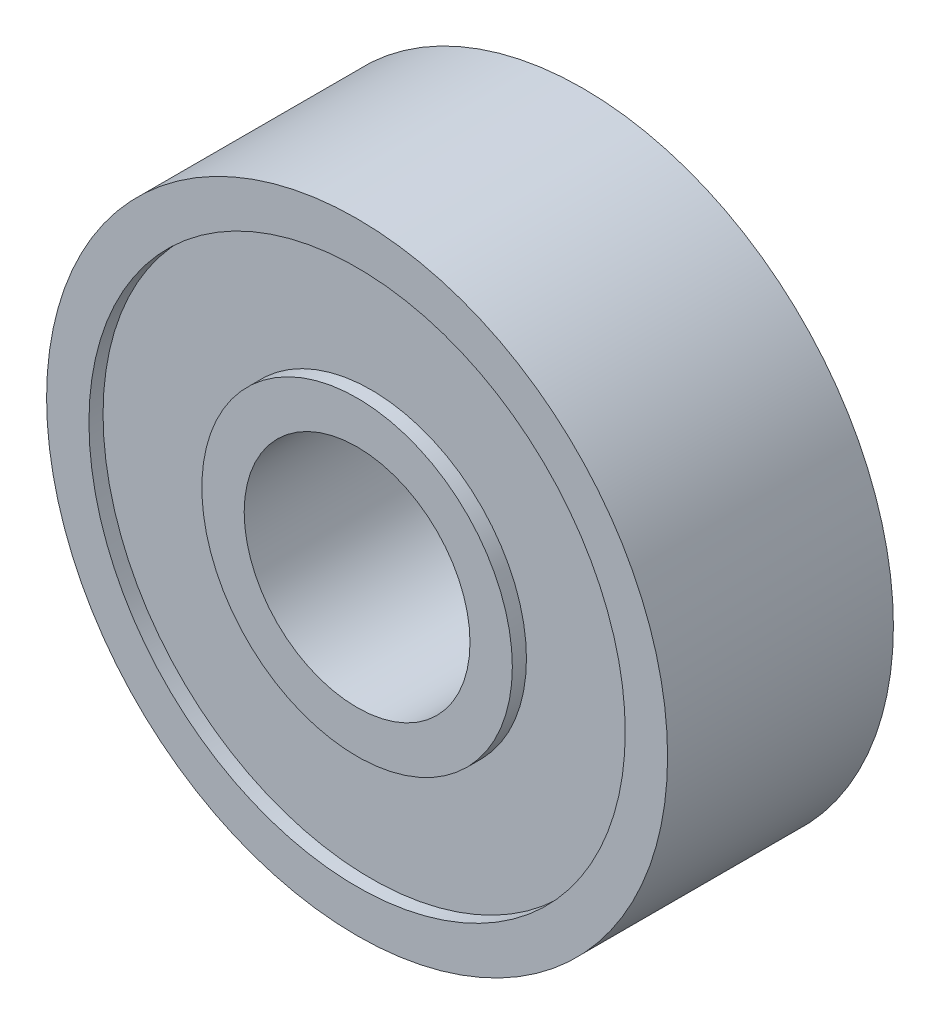
from build123d import *

# Parameters (mm, degrees)
SALIENTE_EXTRUIR1_DEPTH        = 4
SALIENTE_EXTRUIR1_DEPTH_BACK   = 4
CROQUIS1_R                     = 11
CROQUIS1_R_2                   = 9.5
SALIENTE_EXTRUIR1_2_DEPTH      = 4
SALIENTE_EXTRUIR1_2_DEPTH_BACK = 4
CROQUIS1_R_3                   = 5.5
CROQUIS1_R_4                   = 4
SALIENTE_EXTRUIR2_DEPTH        = 3.5
SALIENTE_EXTRUIR2_DEPTH_BACK   = 3.5
CROQUIS1_4_R                   = 9.5
CROQUIS1_4_R_2                 = 5.5


with BuildPart() as part:
    # Croquis1 → Saliente-Extruir1 (new, two sides: drawn at the far end of the back side and taken through both)
    with BuildSketch(Plane.XY.offset(-SALIENTE_EXTRUIR1_DEPTH_BACK)):
        Circle(CROQUIS1_R)
        Circle(CROQUIS1_R_2, mode=Mode.SUBTRACT)
    extrude(amount=SALIENTE_EXTRUIR1_DEPTH + SALIENTE_EXTRUIR1_DEPTH_BACK)



with BuildPart() as body_2:
    # Croquis1 → Saliente-Extruir1 2 (new, two sides: drawn at the far end of the back side and taken through both)
    with BuildSketch(Plane.XY.offset(-SALIENTE_EXTRUIR1_2_DEPTH_BACK)):
        Circle(CROQUIS1_R_3)
        Circle(CROQUIS1_R_4, mode=Mode.SUBTRACT)
    extrude(amount=SALIENTE_EXTRUIR1_2_DEPTH + SALIENTE_EXTRUIR1_2_DEPTH_BACK)


with BuildPart() as part_1:
    add(part.part)

    add(body_2.part)  # Saliente-Extruir2 merges body 2
    # Croquis1_4 → Saliente-Extruir2 (add, two sides: drawn at the far end of the back side and taken through both)
    with BuildSketch(Plane.XY.offset(-SALIENTE_EXTRUIR2_DEPTH_BACK)):
        Circle(CROQUIS1_4_R)
        Circle(CROQUIS1_4_R_2, mode=Mode.SUBTRACT)
    extrude(amount=SALIENTE_EXTRUIR2_DEPTH + SALIENTE_EXTRUIR2_DEPTH_BACK)


solid = part_1.part
